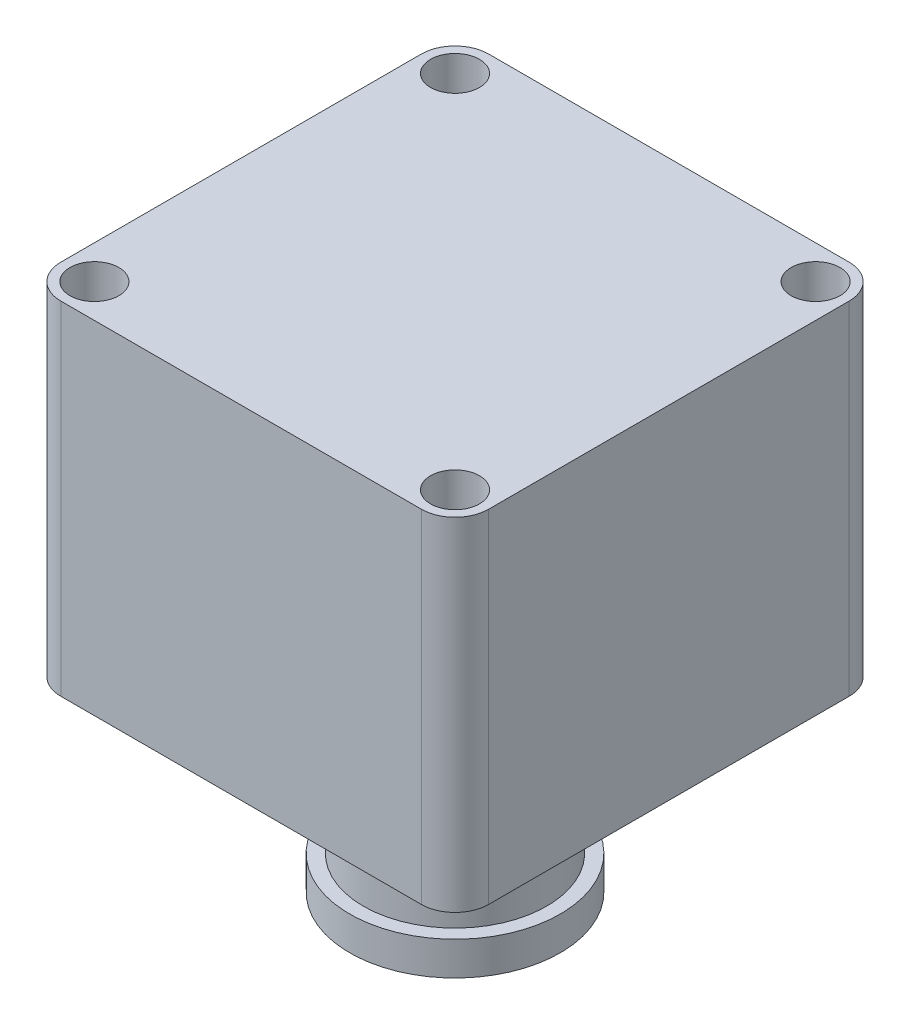
from build123d import *

# Parameters (mm, degrees)
SKETCH1_R           = 4.064
BOSS_EXTRUDE1_DEPTH = 56.896
SKETCH2_R           = 15.24
BOSS_EXTRUDE2_DEPTH = 25.4
SKETCH3_R           = 17.501560838
BOSS_EXTRUDE3_DEPTH = 5.588


with BuildPart() as part:
    # Sketch1 → Boss-Extrude1 (new body)
    with BuildSketch(Plane(origin=(0, 0, 0), x_dir=(1, 0, 0), z_dir=(0, 1, 0))):
        with BuildLine():
            Line((-80.173724845, 32.537607562), (-20.229724845, 32.537607562))
            ThreePointArc((-20.229724845, 32.537607562), (-16.278412152, 30.900920256), (-14.641724845, 26.949607562))
            Line((-14.641724845, 26.949607562), (-14.641724845, -32.994392438))
            ThreePointArc((-14.641724845, -32.994392438), (-16.278412152, -36.945705131), (-20.229724845, -38.582392438))
            Line((-20.229724845, -38.582392438), (-80.173724845, -38.582392438))
            ThreePointArc((-80.173724845, -38.582392438), (-84.125037539, -36.945705131), (-85.761724845, -32.994392438))
            Line((-85.761724845, -32.994392438), (-85.761724845, 26.949607562))
            ThreePointArc((-85.761724845, 26.949607562), (-84.125037539, 30.900920256), (-80.173724845, 32.537607562))
        make_face()
        with Locations((-80.173724845, 26.949607562)):
            Circle(SKETCH1_R, mode=Mode.SUBTRACT)
        with Locations((-80.173724845, -32.994392438)):
            Circle(SKETCH1_R, mode=Mode.SUBTRACT)
        with Locations((-20.229724845, 26.949607562)):
            Circle(SKETCH1_R, mode=Mode.SUBTRACT)
        with Locations((-20.229724845, -32.994392438)):
            Circle(SKETCH1_R, mode=Mode.SUBTRACT)
    extrude(amount=BOSS_EXTRUDE1_DEPTH)

    # Sketch2 → Boss-Extrude2 (add)
    with BuildSketch(Plane.XZ):
        with Locations((-50.201724845, 3.022392438)):
            Circle(SKETCH2_R)
    extrude(amount=BOSS_EXTRUDE2_DEPTH)

    # Sketch3 → Boss-Extrude3 (add)
    with BuildSketch(Plane.XZ.offset(25.4)):
        with Locations((-50.201724845, 3.022392438)):
            Circle(SKETCH3_R)
    extrude(amount=BOSS_EXTRUDE3_DEPTH)


solid = part.part
